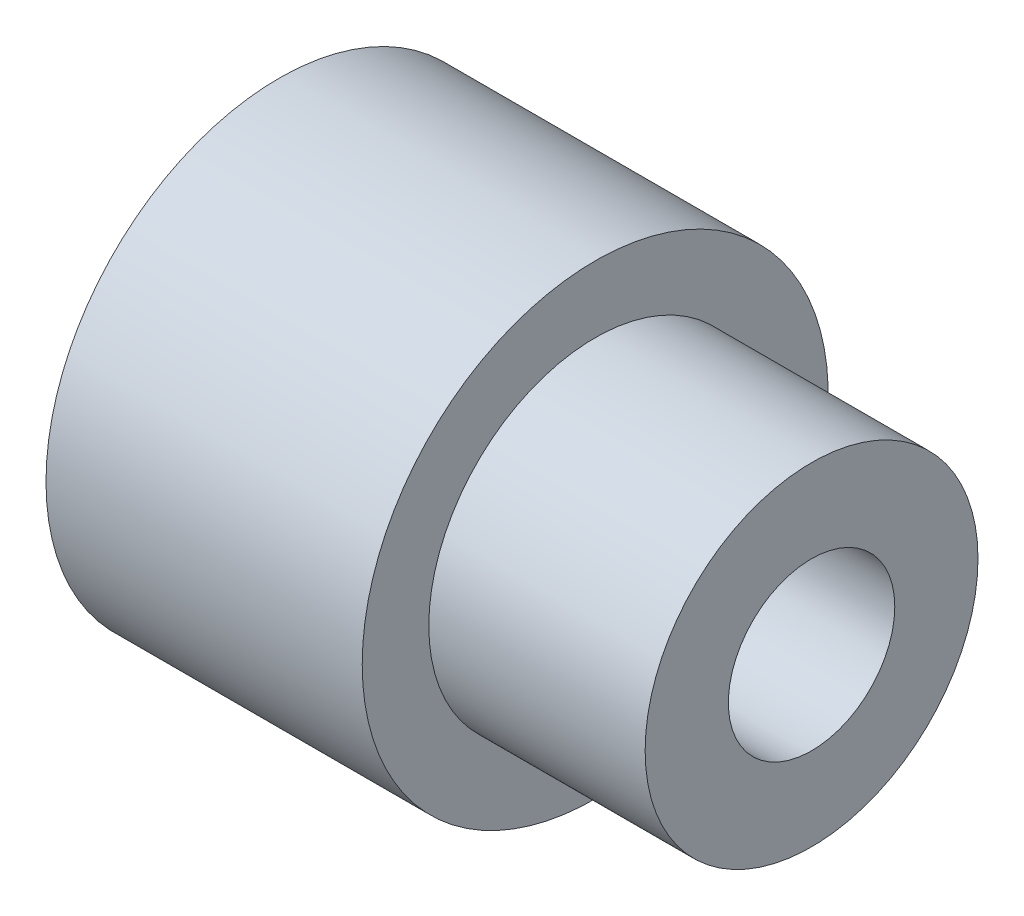
from build123d import *

# Parameters (mm, degrees)
SKETCH2_R               = 11
CUT_EXTRUDE2_DEPTH      = 6
SKETCH6_R               = 9
CUT_EXTRUDE3_DEPTH      = 10
SKETCH7_R               = 5
CUT_EXTRUDE4_DEPTH      = 1
CUT_EXTRUDE4_DEPTH_BACK = 33


with BuildPart() as part:
    # Sketch1 → Revolve1 (revolve)
    with BuildSketch(Plane.XY):
        Polygon((-20.809912875, 0), (-20.809912875, -14), (-1.809912875, -14), (-1.809912875, -10), (11.190087125, -10), (11.190087125, 0), align=None)
    revolve(axis=Axis((-20.809912875, 0, 0), (1, 0, 0)))

    # Sketch2 → Cut-Extrude2 (cut)
    with BuildSketch(Plane.ZY.offset(20.809912875)):
        Circle(SKETCH2_R)
    extrude(amount=-CUT_EXTRUDE2_DEPTH, mode=Mode.SUBTRACT)

    # Sketch6 → Cut-Extrude3 (cut)
    with BuildSketch(Plane.ZY.offset(14.809912875)):
        Circle(SKETCH6_R)
    extrude(amount=-CUT_EXTRUDE3_DEPTH, mode=Mode.SUBTRACT)

    # Sketch7 → Cut-Extrude4 (cut, two sides)
    with BuildSketch(Plane(origin=(11.190087125, 0, 0), x_dir=(0, 0, -1), z_dir=(1, 0, 0))) as cut_extrude4_sk:
        Circle(SKETCH7_R)
    extrude(amount=CUT_EXTRUDE4_DEPTH, mode=Mode.SUBTRACT)
    extrude(cut_extrude4_sk.sketch, amount=-CUT_EXTRUDE4_DEPTH_BACK, mode=Mode.SUBTRACT)


solid = part.part
